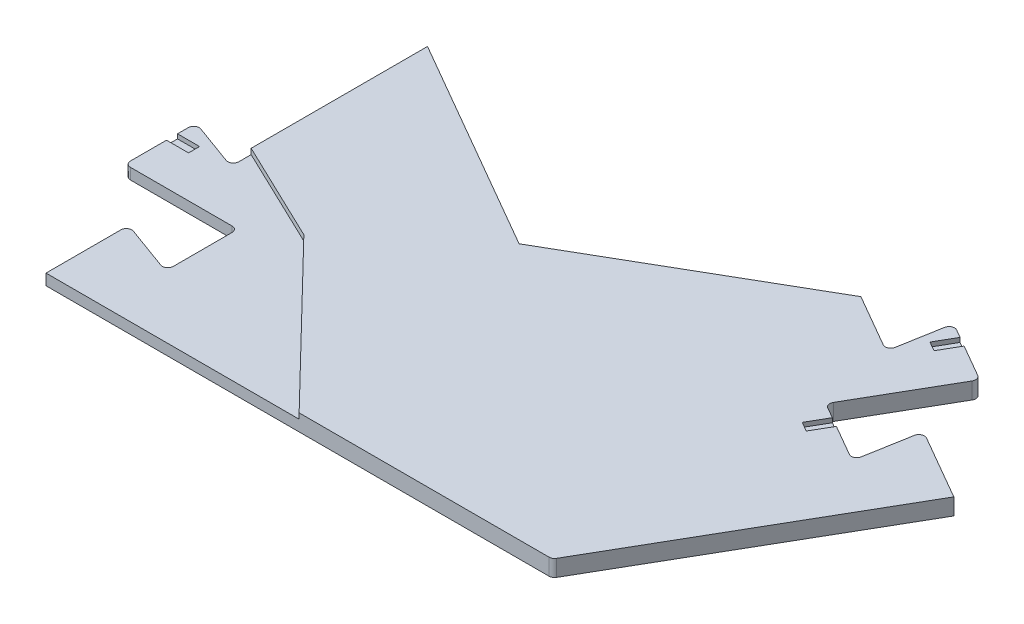
from build123d import *

# Parameters (mm, degrees)
P_IDAT_VYSUNUT_M1_DEPTH  = 3
P_IDAT_VYSUNUT_M2_DEPTH  = 2
ZAOBLIT1_R               = 1
SKICA3_W                 = 4
SKICA3_H                 = 2
ODEBRAT_VYSUNUT_M1_DEPTH = 0.8
ODEBRAT_VYSUNUT_M2_DEPTH = 0.8


with BuildPart() as part:
    # Skica1 → P_idat vysunut_m1 (new body)
    with BuildSketch(Plane(origin=(0, 0, 0), x_dir=(1, 0, 0), z_dir=(0, 1, 0))):
        Polygon((26.667853432, 46.190077074), (13.677472376, 53.690077074), (11.737150801, 42.685966604), (0.392218012, 49.235966604), (10.61747027, 66.946623035), (-0.554257439, 73.396623035), (-2.393036353, 62.968389614), (-13.22114317, 69.22), (-52.538696502, 46.52), (-91.856249834, 69.22), (-91.856249834, 37.22), (-73.49138407, 28.419769911), (-45.928124917, 0), (0, 0), align=None)
    extrude(amount=P_IDAT_VYSUNUT_M1_DEPTH)

    # Skica1_15 → P_idat vysunut_m2 (add)
    with BuildSketch(Plane(origin=(0, 0, 0), x_dir=(1, 0, 0), z_dir=(0, 1, 0))):
        Polygon((13.677472376, 53.690077074), (26.667853432, 46.190077074), (0, 0), (-91.856249834, 0), (-91.856249834, 15), (-81.356249834, 11.17831254), (-81.356249834, 24.27831254), (-101.80675435, 24.27831254), (-101.80675435, 37.17831254), (-91.856249834, 33.55662508), (-91.856249834, 69.22), (-52.538696502, 46.52), (-13.22114317, 69.22), (-2.393036353, 62.968389614), (-0.554257439, 73.396623035), (10.61747027, 66.946623035), (0.392218012, 49.235966604), (11.737150801, 42.685966604), align=None)
    extrude(amount=P_IDAT_VYSUNUT_M2_DEPTH)

    # Zaoblit1
    zaoblit1_edges = [part.edges().sort_by_distance(p)[0] for p in [
        (10.61747027, 1.5, -66.946623035),
        (0.392218012, 1.5, -49.235966604),
        (11.737150801, 1.5, -42.685966604),
        (13.677472376, 1.5, -53.690077074),
        (0, 1.5, 0),
        (-2.393036353, 1.5, -62.968389614),
        (-0.554257439, 1.5, -73.396623035),
        (-91.856249834, 1, -33.55662508),
        (-101.80675435, 1, -37.17831254),
        (-101.80675435, 1, -24.27831254),
        (-81.356249834, 1, -24.27831254),
        (-81.356249834, 1, -11.17831254),
        (-91.856249834, 1, -15),
    ]]
    fillet(zaoblit1_edges, radius=ZAOBLIT1_R)

    # Skica3 → Odebrat vysunut_m1 (cut)
    with BuildSketch(Plane(origin=(0, 2, 0), x_dir=(1, 0, 0), z_dir=(0, 1, 0))):
        with Locations((-99.80675435, 32.814238537)):
            Rectangle(SKICA3_W, SKICA3_H)
    extrude(amount=-ODEBRAT_VYSUNUT_M1_DEPTH, mode=Mode.SUBTRACT)

    # Skica4 → Odebrat vysunut_m2 (cut)
    with BuildSketch(Plane(origin=(0, 3, 0), x_dir=(1, 0, 0), z_dir=(0, 1, 0))):
        Polygon((1.206800574, 44.146864989), (3.206800574, 47.610966604), (4.938851381, 46.610966604), (2.938851381, 43.146864989), align=None)
        Polygon((0.173722583, 68.35752142), (2.173722583, 71.821623035), (3.90577339, 70.821623035), (1.90577339, 67.35752142), align=None)
    extrude(amount=-ODEBRAT_VYSUNUT_M2_DEPTH, mode=Mode.SUBTRACT)


solid = part.part
